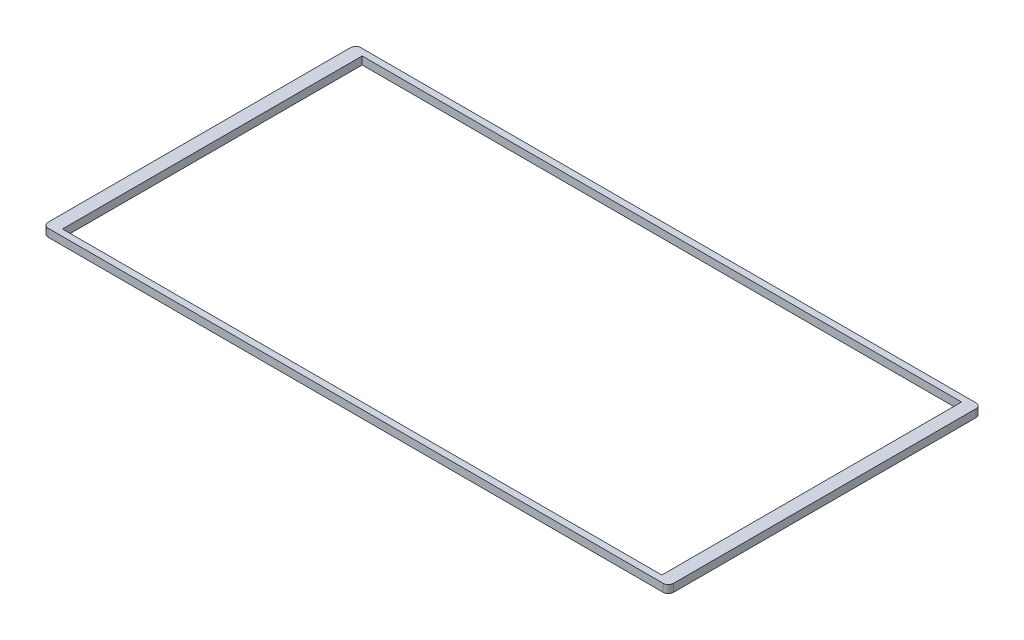
from build123d import *

# Parameters (mm, degrees)
SKETCH1_W           = 2400
SKETCH1_H           = 1200
SKETCH1_W_2         = 2300
SKETCH1_H_2         = 1150
BOSS_EXTRUDE1_DEPTH = 15
FILLET1_R           = 20


with BuildPart() as part:
    # Sketch1 → Boss-Extrude1 (new body, symmetric)
    with BuildSketch(Plane(origin=(0, 0, 0), x_dir=(1, 0, 0), z_dir=(0, 1, 0))):
        Rectangle(SKETCH1_W, SKETCH1_H)
        Rectangle(SKETCH1_W_2, SKETCH1_H_2, mode=Mode.SUBTRACT)
    extrude(amount=BOSS_EXTRUDE1_DEPTH, both=True)

    # Fillet1
    fillet1_edges = [part.edges().sort_by_distance(p)[0] for p in [
        (1200, 0, 600),
        (-1200, 0, 600),
        (-1200, 0, -600),
        (1200, 0, -600),
    ]]
    fillet(fillet1_edges, radius=FILLET1_R)


solid = part.part
